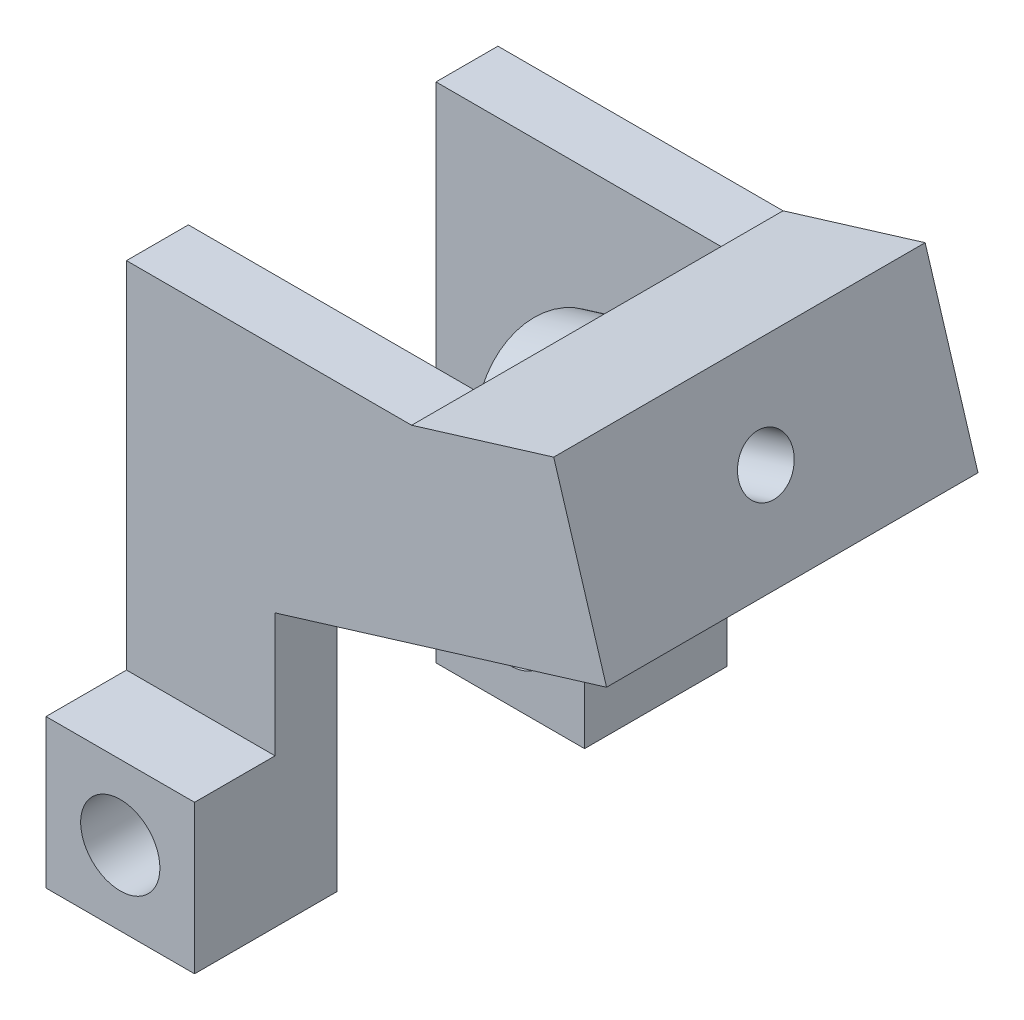
from build123d import *

# Parameters (mm, degrees)
BOSS_EXTRUDE1_DEPTH     = 9.525
SKETCH2_W               = 12.7
SKETCH2_H               = 25.806397913
CUT_EXTRUDE1_DEPTH      = 14.822389654
CUT_EXTRUDE1_DEPTH_BACK = 4.513666667
SKETCH3_W               = 19.05
SKETCH3_H               = 9.271
SKETCH3_R               = 1.397
BOSS_EXTRUDE2_DEPTH     = 7.62
SKETCH3_3_R             = 4.064
SKETCH3_3_R_2           = 1.397
BOSS_EXTRUDE3_DEPTH     = 3.556
SKETCH4_W               = 4.1275
SKETCH4_H               = 7.62
BOSS_EXTRUDE4_DEPTH     = 7.62
SKETCH5_R               = 2.032
CUT_EXTRUDE2_DEPTH      = 20.0025


with BuildPart() as part:
    # Sketch1 → Boss-Extrude1 (new body, symmetric)
    with BuildSketch(Plane.XY):
        Polygon((-3.513666667, -7.641166667), (4.106333333, -7.641166667), (4.106333333, 6.328833333), (13.822389654, 9.299329853), (11.111811579, 18.165231246), (-3.513666667, 18.165231246), align=None)
    extrude(amount=BOSS_EXTRUDE1_DEPTH, both=True)

    # Sketch2 → Cut-Extrude1 (cut, two sides)
    with BuildSketch(Plane(origin=(0, 0, 0), x_dir=(0, 0, -1), z_dir=(1, 0, 0))) as cut_extrude1_sk:
        with Locations((0, 5.26203229)):
            Rectangle(SKETCH2_W, SKETCH2_H)
    extrude(amount=CUT_EXTRUDE1_DEPTH, mode=Mode.SUBTRACT)
    extrude(cut_extrude1_sk.sketch, amount=-CUT_EXTRUDE1_DEPTH_BACK, mode=Mode.SUBTRACT)

    # Sketch3 → Boss-Extrude2 (add)
    with BuildSketch(Plane(origin=(15.24089464, 4.659609104, 0), x_dir=(0, 0, -1), z_dir=(0.956304756, 0.292371705, 0))):
        with Locations((0, 9.48721774)):
            Rectangle(SKETCH3_W, SKETCH3_H)
        with Locations((0, 9.48721774)):
            Circle(SKETCH3_R, mode=Mode.SUBTRACT)
    extrude(amount=BOSS_EXTRUDE2_DEPTH)

    # Sketch3_3 → Boss-Extrude3 (add)
    with BuildSketch(Plane(origin=(15.24089464, 4.659609104, 0), x_dir=(0, 0, -1), z_dir=(0.956304756, 0.292371705, 0))):
        with Locations((0, 9.48721774)):
            Circle(SKETCH3_3_R)
        with Locations((0, 9.48721774)):
            Circle(SKETCH3_3_R_2, mode=Mode.SUBTRACT)
    extrude(amount=-BOSS_EXTRUDE3_DEPTH)

    # Sketch4 → Boss-Extrude4 (add)
    with BuildSketch(Plane(origin=(4.106333333, 0, 0), x_dir=(0, 0, -1), z_dir=(1, 0, 0))):
        with Locations((-11.58875, -3.831166667)):
            Rectangle(SKETCH4_W, SKETCH4_H)
    boss_extrude4 = extrude(amount=-BOSS_EXTRUDE4_DEPTH)

    # Sketch5 → Cut-Extrude2 (cut)
    with BuildSketch(Plane.XY.offset(13.6525)):
        with Locations((0.296333333, -3.831166667)):
            Circle(SKETCH5_R)
    cut_extrude2 = extrude(amount=-CUT_EXTRUDE2_DEPTH, mode=Mode.SUBTRACT)

    # Mirror1: Boss-Extrude4, Cut-Extrude2 across plane
    add(boss_extrude4.mirror(Plane.XY))
    add(cut_extrude2.mirror(Plane.XY), mode=Mode.SUBTRACT)


solid = part.part
